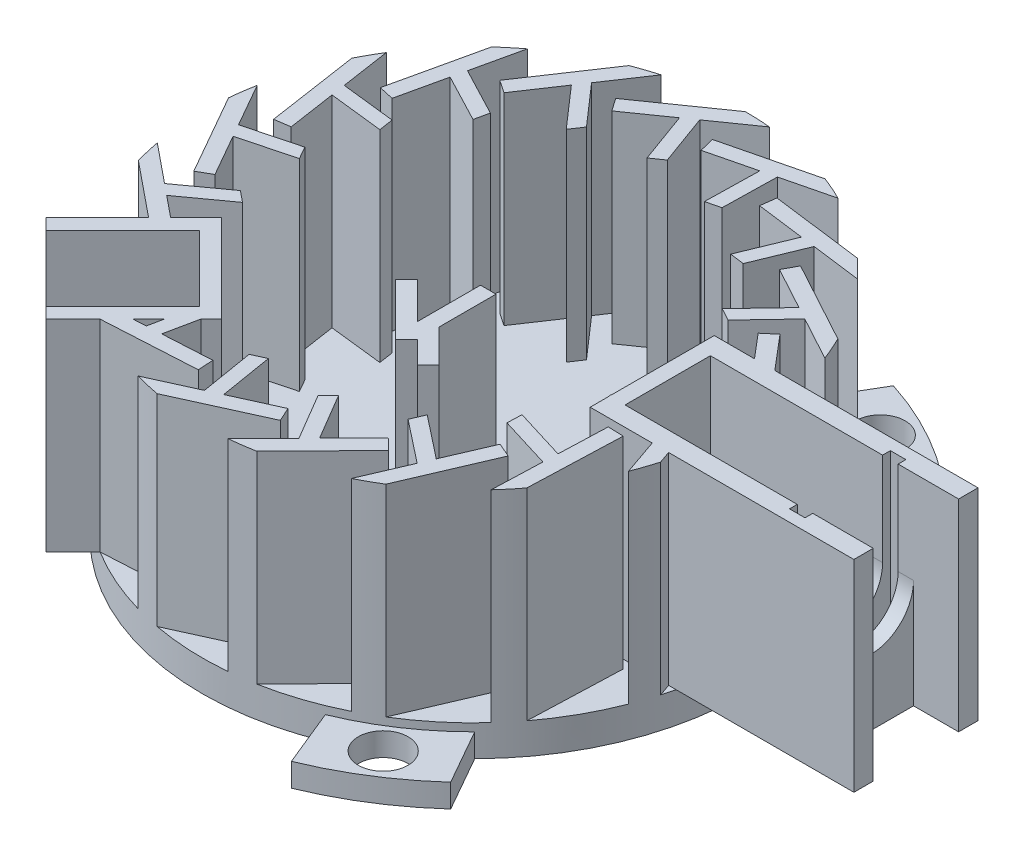
from build123d import *

# Parameters (mm, degrees)
SKETCH1_R           = 17.5
BOSS_EXTRUDE1_DEPTH = 2
BOSS_EXTRUDE2_DEPTH = 13
SKETCH7_W           = 17
SKETCH7_H           = 8
BOSS_EXTRUDE3_DEPTH = 13
SKETCH8_W           = 15
SKETCH8_H           = 5.5
CUT_EXTRUDE1_DEPTH  = 6
SKETCH10_W          = 3.5
SKETCH10_H          = 5.5
CUT_EXTRUDE2_DEPTH  = 6
CUT_EXTRUDE3_START  = -1
SKETCH14_R          = 2.75
CUT_EXTRUDE3_DEPTH  = 13
SKETCH15_W          = 1.905618148
SKETCH15_H          = 1.75
CUT_EXTRUDE4_DEPTH  = 13
SKETCH16_W          = 2.905618148
SKETCH16_H          = 5.502957148
CUT_EXTRUDE5_DEPTH  = 13
SKETCH17_W          = 1
SKETCH17_H          = 0.5
SKETCH17_H_2        = 5.5
CUT_EXTRUDE6_DEPTH  = 10
SKETCH18_R          = 2
CUT_EXTRUDE7_DEPTH  = 10
BOSS_EXTRUDE4_DEPTH = 13
CUT_EXTRUDE8_DEPTH  = 6
CUT_EXTRUDE9_DEPTH  = 7
SKETCH23_R          = 2.6
CUT_EXTRUDE10_DEPTH = 3
CUT_EXTRUDE11_DEPTH = 22
CUT_EXTRUDE12_DEPTH = 17
CUT_EXTRUDE15_DEPTH = 22
BOSS_EXTRUDE5_DEPTH = 13
CUT_EXTRUDE16_DEPTH = 13
BOSS_EXTRUDE6_DEPTH = 1.5
SKETCH31_R          = 1.6
CUT_EXTRUDE17_DEPTH = 16.5


with BuildPart() as part:
    # Sketch1 → Boss-Extrude1 (new body)
    with BuildSketch(Plane(origin=(0, 0, 0), x_dir=(1, 0, 0), z_dir=(0, 1, 0))):
        Circle(SKETCH1_R)
    extrude(amount=BOSS_EXTRUDE1_DEPTH)

    # Sketch6 → Boss-Extrude2 (add)
    with BuildSketch(Plane(origin=(0, 2, 0), x_dir=(1, 0, 0), z_dir=(0, 1, 0))):
        with BuildLine():
            Line((0, 17.5), (-4.914912266, 14.058541382))
            Line((-4.914912266, 14.058541382), (-4.341335829, 13.239389338))
            Line((-4.341335829, 13.239389338), (-1.777576333, 15.034553063))
            Line((-1.777576333, 15.034553063), (-0.580505831, 11.745628891))
            Line((-0.580505831, 11.745628891), (0.18864202, 12.284192014))
            Line((0.18864202, 12.284192014), (-1.008428482, 15.573116187))
            Line((-1.008428482, 15.573116187), (1.634231764, 17.423526811))
            ThreePointArc((1.634231764, 17.423526811), (0.818010025, 17.480871248), (0, 17.5))
        make_face()
        with BuildLine():
            Line((6.321729158, 16.318264015), (0.495511715, 14.884670521))
            Line((0.495511715, 14.884670521), (0.734443964, 13.91363428))
            Line((0.734443964, 13.91363428), (3.773566433, 14.661437849))
            Line((3.773566433, 14.661437849), (3.701704984, 11.162175651))
            Line((3.701704984, 11.162175651), (4.613465436, 11.386522556))
            Line((4.613465436, 11.386522556), (4.685326884, 14.885784754))
            Line((4.685326884, 14.885784754), (7.817979592, 15.656602285))
            ThreePointArc((7.817979592, 15.656602285), (7.077590688, 16.00492768), (6.321729158, 16.318264015))
        make_face()
        with BuildLine():
            Line((11.789673764, 12.932656051), (5.839014093, 13.700542427))
            Line((5.839014093, 13.700542427), (5.711033031, 12.708765815))
            Line((5.711033031, 12.708765815), (8.815068142, 12.308214212))
            Line((8.815068142, 12.308214212), (7.48398003, 9.071208738))
            Line((7.48398003, 9.071208738), (8.41521478, 8.951040132))
            Line((8.41521478, 8.951040132), (9.746302893, 12.188045606))
            Line((9.746302893, 12.188045606), (12.945865956, 11.775166863))
            ThreePointArc((12.945865956, 11.775166863), (12.38130351, 12.367429943), (11.789673764, 12.932656051))
        make_face()
        with BuildLine():
            Line((15.665357599, 7.800421226), (10.393925263, 10.666080161))
            Line((10.393925263, 10.666080161), (9.916315441, 9.787508105))
            Line((9.916315441, 9.787508105), (12.666046052, 8.292698043))
            Line((12.666046052, 8.292698043), (10.255502102, 5.75512482))
            Line((10.255502102, 5.75512482), (11.080442739, 5.306670139))
            Line((11.080442739, 5.306670139), (13.490986689, 7.844243362))
            Line((13.490986689, 7.844243362), (16.325341387, 6.303429908))
            ThreePointArc((16.325341387, 6.303429908), (16.012852686, 7.059642261), (15.665357599, 7.800421226))
        make_face()
        with BuildLine():
            Line((17.425348085, 1.614696291), (13.545079231, 6.191104666))
            Line((13.545079231, 6.191104666), (12.782344502, 5.544393191))
            Line((12.782344502, 5.544393191), (14.806404258, 3.157207052))
            Line((14.806404258, 3.157207052), (11.641961788, 1.661779404))
            Line((11.641961788, 1.661779404), (12.249195506, 0.945604938))
            Line((12.249195506, 0.945604938), (15.413637977, 2.441032586))
            Line((15.413637977, 2.441032586), (17.499989001, -0.019620184))
            ThreePointArc((17.499989001, -0.019620184), (17.481777376, 0.798410773), (17.425348085, 1.614696291))
        make_face()
        with BuildLine():
            Line((16.831948756, -4.789102326), (14.866895193, 0.879986181))
            Line((14.866895193, 0.879986181), (13.922047109, 0.552477253))
            Line((13.922047109, 0.552477253), (14.947075524, -2.404682246))
            Line((14.947075524, -2.404682246), (11.456110024, -2.655998528))
            Line((11.456110024, -2.655998528), (11.763626545, -3.543169449))
            Line((11.763626545, -3.543169449), (15.254592046, -3.291853167))
            Line((15.254592046, -3.291853167), (16.311166131, -6.340020462))
            ThreePointArc((16.311166131, -6.340020462), (16.589691162, -5.570650514), (16.831948756, -4.789102326))
        make_face()
        with BuildLine():
            Line((13.965301477, -10.546106137), (14.180854579, -4.549979315))
            Line((14.180854579, -4.549979315), (13.181500109, -4.514053798))
            Line((13.181500109, -4.514053798), (13.069061416, -7.641805882))
            Line((13.069061416, -7.641805882), (9.72304712, -6.615069142))
            Line((9.72304712, -6.615069142), (9.689314635, -7.553419169))
            Line((9.689314635, -7.553419169), (13.035328931, -8.580155909))
            Line((13.035328931, -8.580155909), (12.919429891, -11.804165845))
            ThreePointArc((12.919429891, -11.804165845), (13.45707523, -11.187364581), (13.965301477, -10.546106137))
        make_face()
        with BuildLine():
            Line((9.21256285, -14.878799875), (11.579610976, -9.365444892))
            Line((11.579610976, -9.365444892), (10.660718478, -8.970936871))
            Line((10.660718478, -8.970936871), (9.425998145, -11.846861289))
            Line((9.425998145, -11.846861289), (6.676832826, -9.680738012))
            Line((6.676832826, -9.680738012), (6.306407093, -10.543537775))
            Line((6.306407093, -10.543537775), (9.055572412, -12.709661052))
            Line((9.055572412, -12.709661052), (7.782853055, -15.674093222))
            ThreePointArc((7.782853055, -15.674093222), (8.50700672, -15.29316307), (9.21256285, -14.878799875))
        make_face()
        with BuildLine():
            Line((3.215616562, -17.202029244), (7.414476745, -12.91605524))
            Line((7.414476745, -12.91605524), (6.700147744, -12.21624521))
            Line((6.700147744, -12.21624521), (4.509901594, -14.451932433))
            Line((4.509901594, -14.451932433), (2.728875261, -11.438969572))
            Line((2.728875261, -11.438969572), (2.071784328, -12.109693181))
            Line((2.071784328, -12.109693181), (3.852810661, -15.122656042))
            Line((3.852810661, -15.122656042), (1.595158788, -17.427147456))
            ThreePointArc((1.595158788, -17.427147456), (2.408019813, -17.333535144), (3.215616562, -17.202029244))
        make_face()
        with BuildLine():
            Line((-3.215616562, -17.202029244), (2.247976344, -14.722280758))
            Line((2.247976344, -14.722280758), (1.83468493, -13.81168194))
            Line((1.83468493, -13.81168194), (-1.015282158, -15.105190021))
            Line((-1.015282158, -15.105190021), (-1.587632029, -11.652304905))
            Line((-1.587632029, -11.652304905), (-2.44264439, -12.040367421))
            Line((-2.44264439, -12.040367421), (-1.87029452, -15.493252537))
            Line((-1.87029452, -15.493252537), (-4.807970512, -16.826568859))
            ThreePointArc((-4.807970512, -16.826568859), (-4.016183513, -17.032917248), (-3.215616562, -17.202029244))
        make_face()
        with BuildLine():
            Line((-9.21256285, -14.878799875), (-3.222125718, -14.540180681))
            Line((-3.222125718, -14.540180681), (-3.27856225, -13.541774492))
            Line((-3.27856225, -13.541774492), (-6.403346429, -13.718407996))
            Line((-6.403346429, -13.718407996), (-5.689720816, -10.291931893))
            Line((-5.689720816, -10.291931893), (-6.627180449, -10.344923322))
            Line((-6.627180449, -10.344923322), (-7.340806061, -13.771399425))
            Line((-7.340806061, -13.771399425), (-10.561756753, -13.953468898))
            ThreePointArc((-10.561756753, -13.953468898), (-9.897979001, -14.431909496), (-9.21256285, -14.878799875))
        make_face()
        with BuildLine():
            Line((-13.965301477, -10.546106137), (-8.257061847, -12.394348632))
            Line((-8.257061847, -12.394348632), (-7.949021431, -11.442975361))
            Line((-7.949021431, -11.442975361), (-10.926603282, -10.478878955))
            Line((-10.926603282, -10.478878955), (-9.02338128, -7.541576449))
            Line((-9.02338128, -7.541576449), (-9.916679065, -7.252340006))
            Line((-9.916679065, -7.252340006), (-11.819901068, -10.189642511))
            Line((-11.819901068, -10.189642511), (-14.88911922, -9.195875644))
            ThreePointArc((-14.88911922, -9.195875644), (-14.442997578, -9.881792396), (-13.965301477, -10.546106137))
        make_face()
        with BuildLine():
            Line((-16.831948756, -4.789102326), (-12.17683602, -8.574591122))
            Line((-12.17683602, -8.574591122), (-11.545921221, -7.798738999))
            Line((-11.545921221, -7.798738999), (-13.974161816, -5.824119245))
            Line((-13.974161816, -5.824119245), (-11.138384101, -3.772689317))
            Line((-11.138384101, -3.772689317), (-11.866875224, -3.180287985))
            Line((-11.866875224, -3.180287985), (-14.702652939, -5.231717913))
            Line((-14.702652939, -5.231717913), (-17.205623632, -3.196328428))
            ThreePointArc((-17.205623632, -3.196328428), (-17.037409301, -3.997084476), (-16.831948756, -4.789102326))
        make_face()
        with BuildLine():
            Line((-17.425348085, 1.614696291), (-14.452061014, -3.596787567))
            Line((-14.452061014, -3.596787567), (-13.583480372, -3.101239722))
            Line((-13.583480372, -3.101239722), (-15.134432363, -0.382779959))
            Line((-15.134432363, -0.382779959), (-11.749086429, 0.505720413))
            Line((-11.749086429, 0.505720413), (-12.214384127, 1.321279551))
            Line((-12.214384127, 1.321279551), (-15.59973006, 0.432779179))
            Line((-15.59973006, 0.432779179), (-17.198413234, 3.234900654))
            ThreePointArc((-17.198413234, 3.234900654), (-17.33082449, 2.427451851), (-17.425348085, 1.614696291))
        make_face()
        with BuildLine():
            Line((-15.665357599, 7.800421226), (-14.775455087, 1.86678208))
            Line((-14.775455087, 1.86678208), (-13.786515229, 2.015099165))
            Line((-13.786515229, 2.015099165), (-14.250713956, 5.110255882))
            Line((-14.250713956, 5.110255882), (-10.773009531, 4.715829799))
            Line((-10.773009531, 4.715829799), (-10.912272771, 5.644400962))
            Line((-10.912272771, 5.644400962), (-14.389977196, 6.038827045))
            Line((-14.389977196, 6.038827045), (-14.868461828, 9.229238477))
            ThreePointArc((-14.868461828, 9.229238477), (-15.283615799, 8.524147354), (-15.665357599, 7.800421226))
        make_face()
        with BuildLine():
            Line((-11.789673764, 12.932656051), (-13.103342077, 7.078232462))
            Line((-13.103342077, 7.078232462), (-12.127604812, 6.859287743))
            Line((-12.127604812, 6.859287743), (-11.442357664, 9.913123349))
            Line((-11.442357664, 9.913123349), (-8.341978001, 8.289040239))
            Line((-8.341978001, 8.289040239), (-8.136398511, 9.205214746))
            Line((-8.136398511, 9.205214746), (-11.236778173, 10.829297856))
            Line((-11.236778173, 10.829297856), (-10.530442264, 13.977116503))
            ThreePointArc((-10.530442264, 13.977116503), (-11.172270104, 13.469609524), (-11.789673764, 12.932656051))
        make_face()
        with BuildLine():
            Line((-6.321729158, 16.318264015), (-9.661550111, 11.333728329))
            Line((-9.661550111, 11.333728329), (-8.830794163, 10.777091503))
            Line((-8.830794163, 10.777091503), (-7.088647565, 13.377168577))
            Line((-7.088647565, 13.377168577), (-4.784316117, 10.742769864))
            Line((-4.784316117, 10.742769864), (-4.261658546, 11.522813271))
            Line((-4.261658546, 11.522813271), (-6.565989994, 14.157211984))
            Line((-6.565989994, 14.157211984), (-4.77022812, 16.837307495))
            ThreePointArc((-4.77022812, 16.837307495), (-5.552047424, 16.595926289), (-6.321729158, 16.318264015))
        make_face()
    extrude(amount=BOSS_EXTRUDE2_DEPTH)

    # Sketch7 → Boss-Extrude3 (add)
    with BuildSketch(Plane(origin=(0, 2, 0), x_dir=(1, 0, 0), z_dir=(0, 1, 0))):
        with Locations((20, 0)):
            Rectangle(SKETCH7_W, SKETCH7_H)
    extrude(amount=BOSS_EXTRUDE3_DEPTH)

    # Sketch8 → Cut-Extrude1 (cut)
    with BuildSketch(Plane(origin=(0, 15, 0), x_dir=(1, 0, 0), z_dir=(0, 1, 0))):
        with Locations((20, 0)):
            Rectangle(SKETCH8_W, SKETCH8_H)
    extrude(amount=-CUT_EXTRUDE1_DEPTH, mode=Mode.SUBTRACT)

    # Sketch10 → Cut-Extrude2 (cut)
    with BuildSketch(Plane(origin=(0, 9, 0), x_dir=(1, 0, 0), z_dir=(0, 1, 0))):
        with Locations((14.25, 0)):
            Rectangle(SKETCH10_W, SKETCH10_H)
    extrude(amount=-CUT_EXTRUDE2_DEPTH, mode=Mode.SUBTRACT)

    # Sketch14 → Cut-Extrude3 (cut)
    with BuildSketch(Plane(origin=(28.5, 0, 0), x_dir=(0, 0, -1), z_dir=(1, 0, 0)).offset(CUT_EXTRUDE3_START)):
        with Locations((0, 9)):
            Circle(SKETCH14_R)
    extrude(amount=-CUT_EXTRUDE3_DEPTH, mode=Mode.SUBTRACT)

    # Sketch15 → Cut-Extrude4 (cut)
    with BuildSketch(Plane(origin=(0, 15, 0), x_dir=(1, 0, 0), z_dir=(0, 1, 0))):
        with Locations((26.547190926, -1.875)):
            Rectangle(SKETCH15_W, SKETCH15_H)
        with Locations((26.547190926, 1.875)):
            Rectangle(SKETCH15_W, SKETCH15_H)
    extrude(amount=-CUT_EXTRUDE4_DEPTH, mode=Mode.SUBTRACT)

    # Sketch16 → Cut-Extrude5 (cut)
    with BuildSketch(Plane(origin=(0, 15, 0), x_dir=(1, 0, 0), z_dir=(0, 1, 0))):
        with Locations((27.047190926, -0.001478574)):
            Rectangle(SKETCH16_W, SKETCH16_H)
    extrude(amount=-CUT_EXTRUDE5_DEPTH, mode=Mode.SUBTRACT)

    # Sketch17 → Cut-Extrude6 (cut)
    with BuildSketch(Plane(origin=(0, 15, 0), x_dir=(1, 0, 0), z_dir=(0, 1, 0))):
        with Locations((24.1, 3)):
            Rectangle(SKETCH17_W, SKETCH17_H)
        with Locations((24.1, 0)):
            Rectangle(SKETCH17_W, SKETCH17_H_2)
        with Locations((24.1, -3)):
            Rectangle(SKETCH17_W, SKETCH17_H)
    extrude(amount=-CUT_EXTRUDE6_DEPTH, mode=Mode.SUBTRACT)

    # Sketch18 → Cut-Extrude7 (cut)
    with BuildSketch(Plane(origin=(12.5, 0, 0), x_dir=(0, 0, -1), z_dir=(1, 0, 0))):
        with Locations((0, 9)):
            Circle(SKETCH18_R)
    extrude(amount=-CUT_EXTRUDE7_DEPTH, mode=Mode.SUBTRACT)

    # Sketch20 → Boss-Extrude4 (add)
    with BuildSketch(Plane(origin=(0, 2, 0), x_dir=(1, 0, 0), z_dir=(0, 1, 0))):
        Polygon((-22.980970389, -17.324116139), (-10.960155108, -5.303300859), (-5.303300859, -10.960155108), (-17.324116139, -22.980970389), align=None)
    extrude(amount=BOSS_EXTRUDE4_DEPTH)

    # Sketch21 → Cut-Extrude8 (cut)
    with BuildSketch(Plane(origin=(0, 15, 0), x_dir=(1, 0, 0), z_dir=(0, 1, 0))):
        Polygon((-17.324116139, -21.566756826), (-6.717514421, -10.960155108), (-10.960155108, -6.717514421), (-21.566756826, -17.324116139), align=None)
    extrude(amount=-CUT_EXTRUDE8_DEPTH, mode=Mode.SUBTRACT)

    # Sketch22 → Cut-Extrude9 (cut)
    with BuildSketch(Plane(origin=(0, 9, 0), x_dir=(1, 0, 0), z_dir=(0, 1, 0))):
        Polygon((-10.960155108, -6.717514421), (-6.717514421, -10.960155108), (-9.545941546, -13.788582233), (-13.788582233, -9.545941546), align=None)
    extrude(amount=-CUT_EXTRUDE9_DEPTH, mode=Mode.SUBTRACT)

    # Sketch23 → Cut-Extrude10 (cut)
    with BuildSketch(Plane(origin=(-11.66726189, 0, 11.66726189), x_dir=(-0.707106781, 0, -0.707106781), z_dir=(0.707106781, 0, -0.707106781))):
        with Locations((0, 9)):
            Circle(SKETCH23_R)
    extrude(amount=-CUT_EXTRUDE10_DEPTH, mode=Mode.SUBTRACT)

    # Sketch24 → Cut-Extrude11 (cut)
    with BuildSketch(Plane(origin=(0, 15, 0), x_dir=(1, 0, 0), z_dir=(0, 1, 0))):
        Polygon((-22.980970389, -17.324116139), (-16.617009358, -10.960155108), (-10.960155108, -16.617009358), (-17.324116139, -22.980970389), align=None)
    extrude(amount=-CUT_EXTRUDE11_DEPTH, mode=Mode.SUBTRACT)

    # Sketch25 → Cut-Extrude12 (cut)
    with BuildSketch(Plane(origin=(-13.788582233, 0, 13.788582233), x_dir=(0.707106781, 0, 0.707106781), z_dir=(-0.707106781, 0, 0.707106781))):
        with BuildLine():
            ThreePointArc((2.6, 9), (0, 11.6), (-2.6, 9))
            ThreePointArc((-2.6, 9), (0, 6.4), (2.6, 9))
        make_face()
    extrude(amount=-CUT_EXTRUDE12_DEPTH, mode=Mode.SUBTRACT)

    # Sketch27 → Cut-Extrude15 (cut)
    with BuildSketch(Plane(origin=(0, 15, 0), x_dir=(1, 0, 0), z_dir=(0, 1, 0))):
        Polygon((-11.313708499, -9.192388155), (-10.960155108, -8.838834765), (-8.838834765, -10.960155108), (-9.545941546, -11.66726189), (-11.66726189, -9.545941546), align=None)
    extrude(amount=-CUT_EXTRUDE15_DEPTH, mode=Mode.SUBTRACT)

    # Sketch28 → Boss-Extrude5 (add)
    with BuildSketch(Plane(origin=(0, 2, 0), x_dir=(1, 0, 0), z_dir=(0, 1, 0))):
        Polygon((-1.911696438, -3.144998494), (1.447060773, -6.503755705), (2.154167554, -5.796648923), (3.568381116, -7.210862486), (4.275487897, -6.503755705), (2.154167554, -4.382435361), (2.154167554, -0.723337101), (1.154167554, -0.723337101), (1.154167554, -4.382435361), (1.154167554, -4.796648923), (-1.204589657, -2.437891713), align=None)
    extrude(amount=BOSS_EXTRUDE5_DEPTH)

    # Sketch29 → Cut-Extrude16 (cut)
    with BuildSketch(Plane(origin=(0, 15, 0), x_dir=(1, 0, 0), z_dir=(0, 1, 0))):
        Polygon((-5.956446946, -10.307009021), (-5.738294991, -10.525160977), (-5.689720816, -10.291931893), align=None)
    extrude(amount=-CUT_EXTRUDE16_DEPTH, mode=Mode.SUBTRACT)

    # Sketch30 → Boss-Extrude6 (add)
    with BuildSketch(Plane(origin=(0, 0, 0), x_dir=(1, 0, 0), z_dir=(0, 1, 0))):
        with BuildLine():
            Line((4.489618927, 16.91429342), (6.576131268, 20.46959935))
            ThreePointArc((6.576131268, 20.46959935), (10.020480713, 19.022091533), (13.162236094, 17.00016297))
            Line((13.162236094, 17.00016297), (10.713447983, 13.837341952))
            ThreePointArc((10.713447983, 13.837341952), (7.75565719, 15.687567738), (4.489618927, 16.91429342))
        make_face()
        with BuildLine():
            Line((12.403398325, -12.345270754), (14.439127409, -15.929896411))
            ThreePointArc((14.439127409, -15.929896411), (11.463374144, -18.189036622), (8.141454954, -19.898912313))
            Line((8.141454954, -19.898912313), (6.62676566, -16.196789092))
            ThreePointArc((6.62676566, -16.196789092), (9.70800359, -14.560380019), (12.403398325, -12.345270754))
        make_face()
        with BuildLine():
            Line((-16.893017252, -4.569022665), (-21.015258676, -4.539702939))
            ThreePointArc((-21.015258676, -4.539702939), (-21.483854857, -0.833054911), (-21.303691048, 2.898749343))
            Line((-21.303691048, 2.898749343), (-17.340213643, 2.359447139))
            ThreePointArc((-17.340213643, 2.359447139), (-17.46366078, -1.127187719), (-16.893017252, -4.569022665))
        make_face()
    extrude(amount=BOSS_EXTRUDE6_DEPTH)

    # Sketch31 → Cut-Extrude17 (cut)
    with BuildSketch(Plane(origin=(0, 2, 0), x_dir=(1, 0, 0), z_dir=(0, 1, 0))):
        with Locations((8.909814561, 17.293808881)):
            Circle(SKETCH31_R)
        with Locations((10.521970538, -16.363030193)):
            Circle(SKETCH31_R)
        with Locations((-19.431785099, -0.930778688)):
            Circle(SKETCH31_R)
    extrude(amount=-CUT_EXTRUDE17_DEPTH, mode=Mode.SUBTRACT)


solid = part.part
